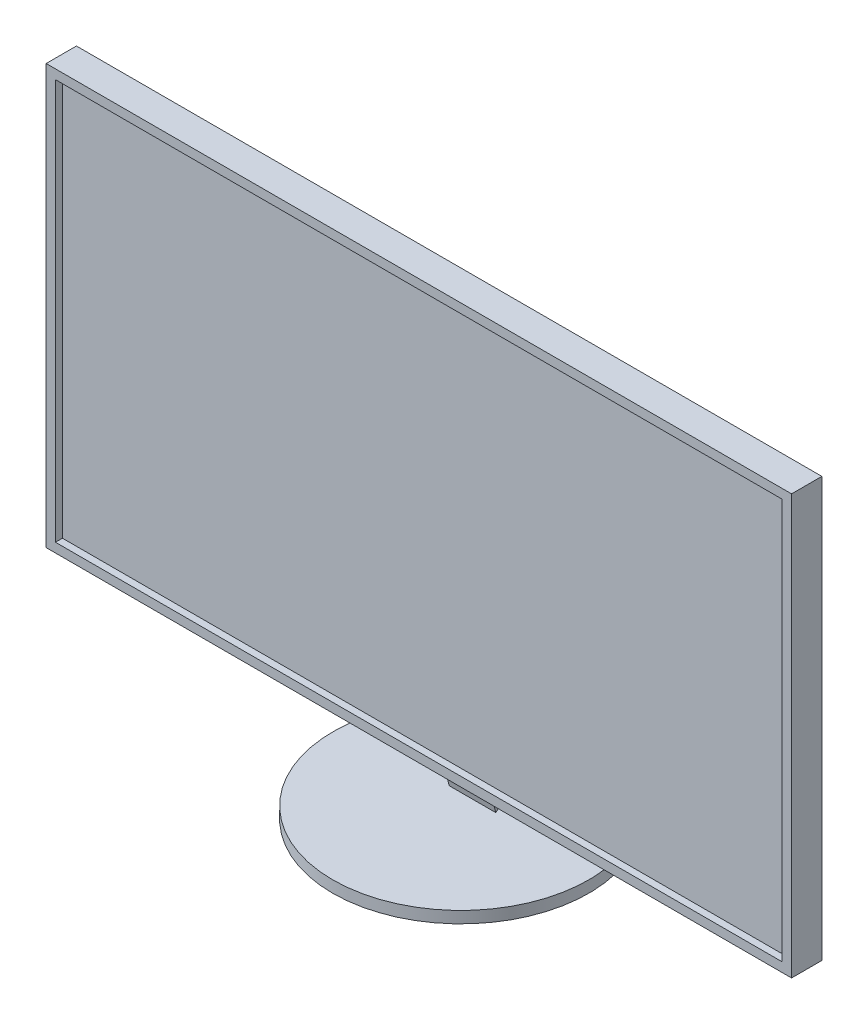
from build123d import *

# Parameters (mm, degrees)
SKETCH1_W           = 160
SKETCH1_H           = 90
BOSS_EXTRUDE1_DEPTH = 2.5
SKETCH2_W           = 160
SKETCH2_H           = 90
SKETCH2_W_2         = 156
SKETCH2_H_2         = 86
BOSS_EXTRUDE2_DEPTH = 1.5
SKETCH3_R           = 27.5
BOSS_EXTRUDE3_DEPTH = 2.5


with BuildPart() as part:
    # Sketch1 → Boss-Extrude1 (new body, symmetric)
    with BuildSketch(Plane.XY):
        Rectangle(SKETCH1_W, SKETCH1_H)
    extrude(amount=BOSS_EXTRUDE1_DEPTH, both=True)

    # Sketch2 → Boss-Extrude2 (add)
    with BuildSketch(Plane.XY.offset(2.5)):
        Rectangle(SKETCH2_W, SKETCH2_H)
        Rectangle(SKETCH2_W_2, SKETCH2_H_2, mode=Mode.SUBTRACT)
    extrude(amount=BOSS_EXTRUDE2_DEPTH)



with BuildPart() as body_2:
    # Sketch3 → Boss-Extrude3 (new body)
    with BuildSketch(Plane(origin=(0, -60, 0), x_dir=(1, 0, 0), z_dir=(0, 1, 0))):
        with Locations((0, 5)):
            Circle(SKETCH3_R)
    extrude(amount=BOSS_EXTRUDE3_DEPTH)


with BuildPart() as part_1:
    add(part.part)

    add(body_2.part)  # Loft1 merges body 2
    # Sketch5 → Loft1 section 0
    with BuildSketch(Plane(origin=(0, 0, -2.5), x_dir=(-1, 0, 0), z_dir=(0, 0, -1))):
        Polygon((0, -22.5), (-5, -37.5), (5, -37.5), align=None)
    # Sketch4 → Loft1 section 1
    with BuildSketch(Plane(origin=(0, -57.5, 0), x_dir=(1, 0, 0), z_dir=(0, 1, 0))):
        Polygon((-5, 7.5), (0, 19.5), (5, 7.5), align=None)
    loft()


solid = part_1.part
